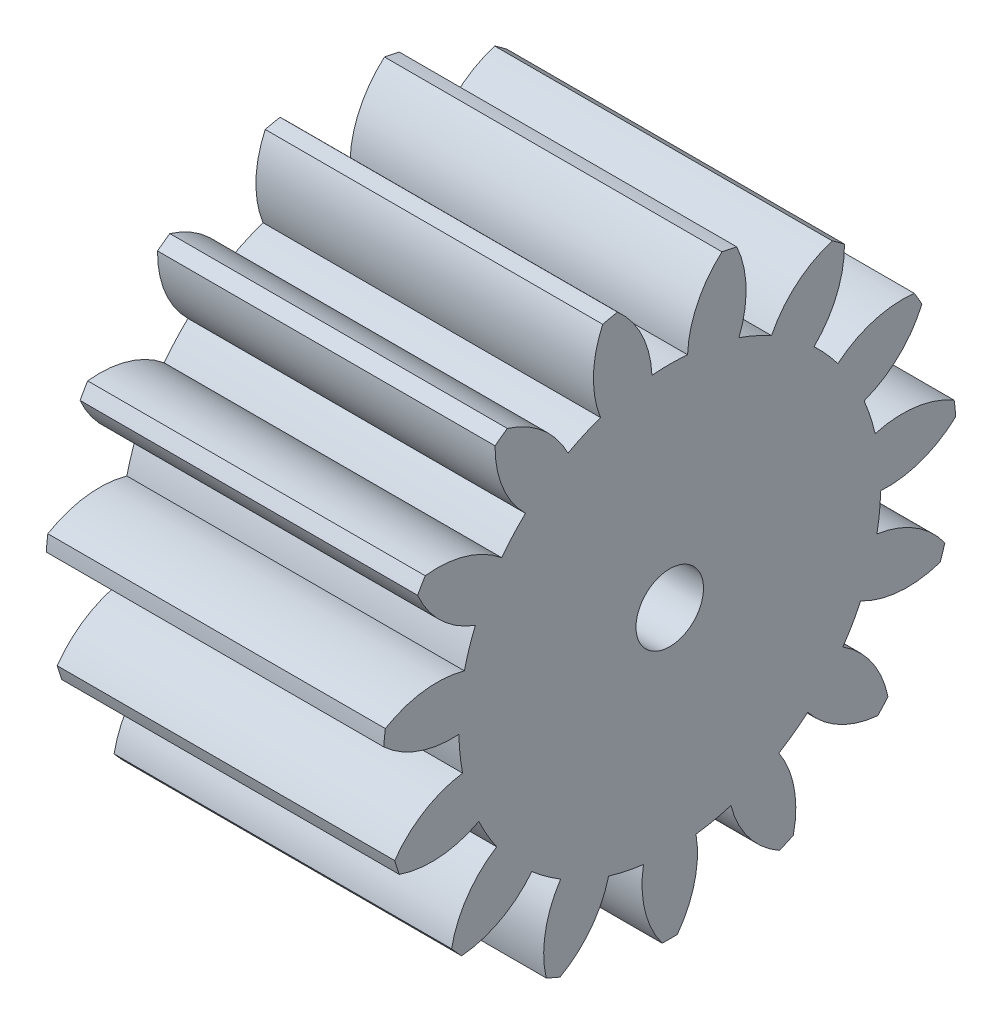
from build123d import *

# Parameters (mm, degrees)
BASPROSKE_W     = 15
BASPROSKE_H     = 12.75
TOOTHCUT_DEPTH  = 24.454743657
TEETHCUTS_COUNT = 15
TEETHCUTS_ANGLE = 336
BORSKE_R        = 1.5
BORE_DEPTH      = 50.0000508


with BuildPart() as part:
    # BasProSke → Base-Revolve (revolve)
    with BuildSketch(Plane(origin=(0, 0, 0), x_dir=(1, 0, 0), z_dir=(0, 1, 0)), mode=Mode.PRIVATE) as base_revolve_sk:
        with Locations((7.5, 6.375)):
            Rectangle(BASPROSKE_W, BASPROSKE_H)
    revolve(base_revolve_sk.sketch.rotate(Axis((-10, 0, 0), (1, 0, 0)), 180), axis=Axis((-10, 0, 0), (1, 0, 0)))

    # TooCutSke → ToothCut (cut, through all)
    with BuildSketch(Plane(origin=(0, 0, 0), x_dir=(0, 0, -1), z_dir=(1, 0, 0))):
        with BuildLine():
            ThreePointArc((0.791546546, 9.340520867), (0, 9.374), (-0.791546546, 9.340520867))
            ThreePointArc((-0.791546546, 9.340520867), (-1.235070734, 11.110218102), (-2.344732916, 12.558386549))
            ThreePointArc((-2.344732916, 12.558386549), (0, 12.7754), (2.344732916, 12.558386549))
            ThreePointArc((2.344732916, 12.558386549), (1.235070734, 11.110218102), (0.791546546, 9.340520867))
        make_face()
    toothcut = extrude(amount=TOOTHCUT_DEPTH, mode=Mode.SUBTRACT)

    # TeethCuts: ToothCut ×15 about axis
    teethcuts_axis = Axis((-10, 0, 0), (1, 0, 0))
    for i in range(1, TEETHCUTS_COUNT):
        add(toothcut.rotate(teethcuts_axis, i * TEETHCUTS_ANGLE / (TEETHCUTS_COUNT - 1)), mode=Mode.SUBTRACT)

    # BorSke → Bore (cut, symmetric)
    with BuildSketch(Plane(origin=(0, 0, 0), x_dir=(0, 0, -1), z_dir=(1, 0, 0))):
        with Locations(Location((0, 0, 0), (0, 0, 180))):
            Circle(BORSKE_R)
    extrude(amount=BORE_DEPTH, both=True, mode=Mode.SUBTRACT)


solid = part.part
